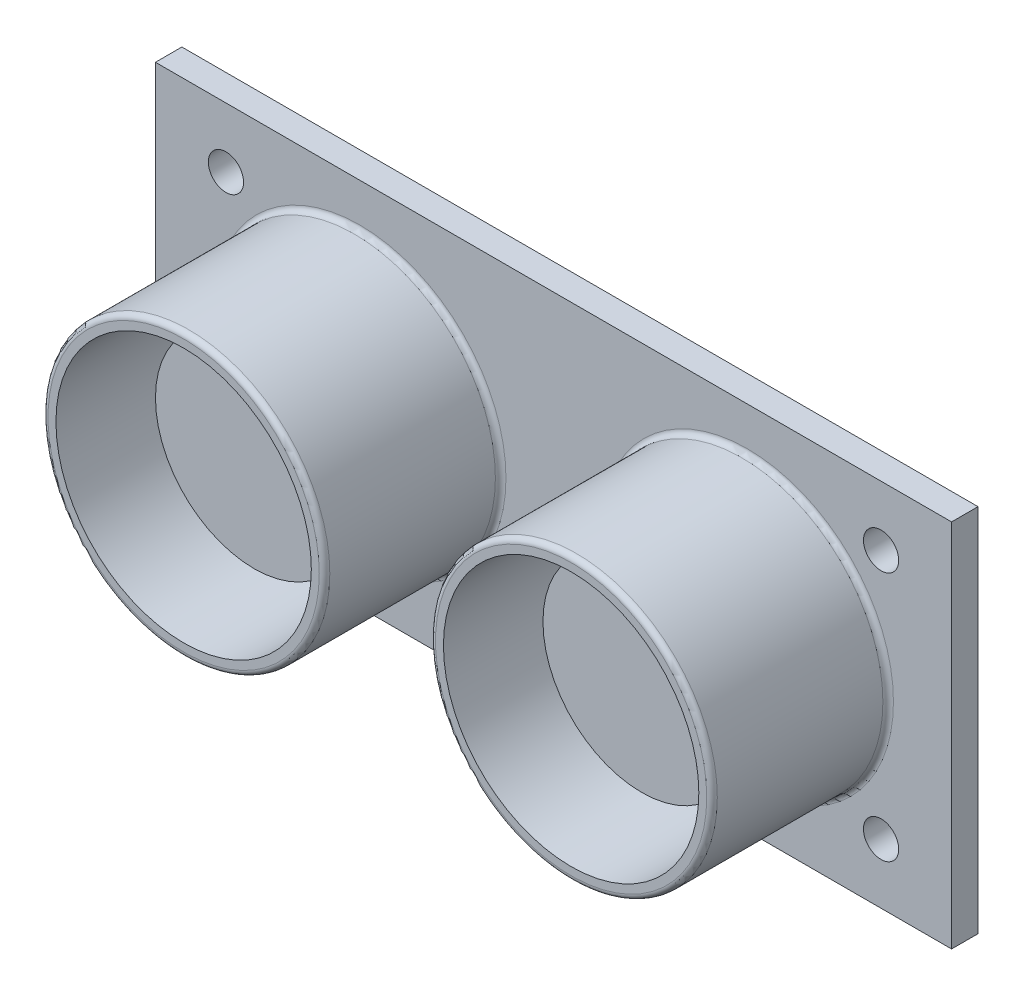
from build123d import *

# Parameters (mm, degrees)
SKETCH1_W               = 45.2
SKETCH1_H               = 21
BOSS_EXTRUDE1_DEPTH     = 0.75
SKETCH2_R               = 1
CUT_EXTRUDE1_DEPTH      = 2.5
MIRROR2_COPY_1_SKETCH_R = 1
MIRROR2_COPY_1_DEPTH    = 2.5
SKETCH3_R               = 8
BOSS_EXTRUDE2_DEPTH     = 10
SKETCH9_R               = 7.25
CUT_EXTRUDE2_DEPTH      = 8
FILLET1_R               = 0.3
SKETCH10_R              = 5.6
BOSS_EXTRUDE3_DEPTH     = 4


with BuildPart() as part:
    # Sketch1 → Boss-Extrude1 (new body, symmetric)
    with BuildSketch(Plane.XY):
        Rectangle(SKETCH1_W, SKETCH1_H)
    extrude(amount=BOSS_EXTRUDE1_DEPTH, both=True)

    # Sketch2 → Cut-Extrude1 (cut, through all)
    with BuildSketch(Plane.XY.offset(0.75)):
        with Locations((-18.596547757, 7.099196252)):
            Circle(SKETCH2_R)
    cut_extrude1 = extrude(amount=-CUT_EXTRUDE1_DEPTH, mode=Mode.SUBTRACT)

    # Mirror1: Cut-Extrude1 across plane
    add(cut_extrude1.mirror(Plane(origin=(0, 0, 0), x_dir=(0, 0, 1), z_dir=(1, 0, 0))), mode=Mode.SUBTRACT)

    # Mirror2: Cut-Extrude1 across plane
    add(cut_extrude1.mirror(Plane.ZX), mode=Mode.SUBTRACT)

    # Mirror2 copy 1 sketch → Mirror2 copy 1 (cut, through all)
    with BuildSketch(Plane(origin=(0, 0, 0.75), x_dir=(-1, 0, 0), z_dir=(0, 0, 1))):
        with Locations((-18.596547757, 7.099196252)):
            Circle(MIRROR2_COPY_1_SKETCH_R)
    extrude(amount=-MIRROR2_COPY_1_DEPTH, mode=Mode.SUBTRACT)

    # Sketch3 → Boss-Extrude2 (add)
    with BuildSketch(Plane.XY.offset(0.75)):
        with Locations((-11, 0)):
            Circle(SKETCH3_R)
    boss_extrude2 = extrude(amount=BOSS_EXTRUDE2_DEPTH)

    # Sketch9 → Cut-Extrude2 (cut)
    with BuildSketch(Plane.XY.offset(10.75)):
        with Locations((-11, 0)):
            Circle(SKETCH9_R)
    cut_extrude2 = extrude(amount=-CUT_EXTRUDE2_DEPTH, mode=Mode.SUBTRACT)

    # Mirror3: Boss-Extrude2 across plane
    add(boss_extrude2.mirror(Plane(origin=(0, 0, 0), x_dir=(0, 0, 1), z_dir=(1, 0, 0))))

    # Mirror4: Cut-Extrude2 across plane
    add(cut_extrude2.mirror(Plane(origin=(0, 0, 0), x_dir=(0, 0, 1), z_dir=(1, 0, 0))), mode=Mode.SUBTRACT)

    # Fillet1
    fillet1_edges = [part.edges().sort_by_distance(p)[0] for p in [
        (-19, 0, 0.75),
        (-19, 0, 10.75),
        (19, 0, 0.75),
        (19, 0, 10.75),
    ]]
    fillet(fillet1_edges, radius=FILLET1_R)

    # Sketch10 → Boss-Extrude3 (add)
    with BuildSketch(Plane.XY.offset(2.75)):
        with Locations((-11, 0)):
            Circle(SKETCH10_R)
    boss_extrude3 = extrude(amount=BOSS_EXTRUDE3_DEPTH)

    # Mirror5: Boss-Extrude3 across plane
    add(boss_extrude3.mirror(Plane(origin=(0, 0, 0), x_dir=(0, 0, 1), z_dir=(1, 0, 0))))


solid = part.part
